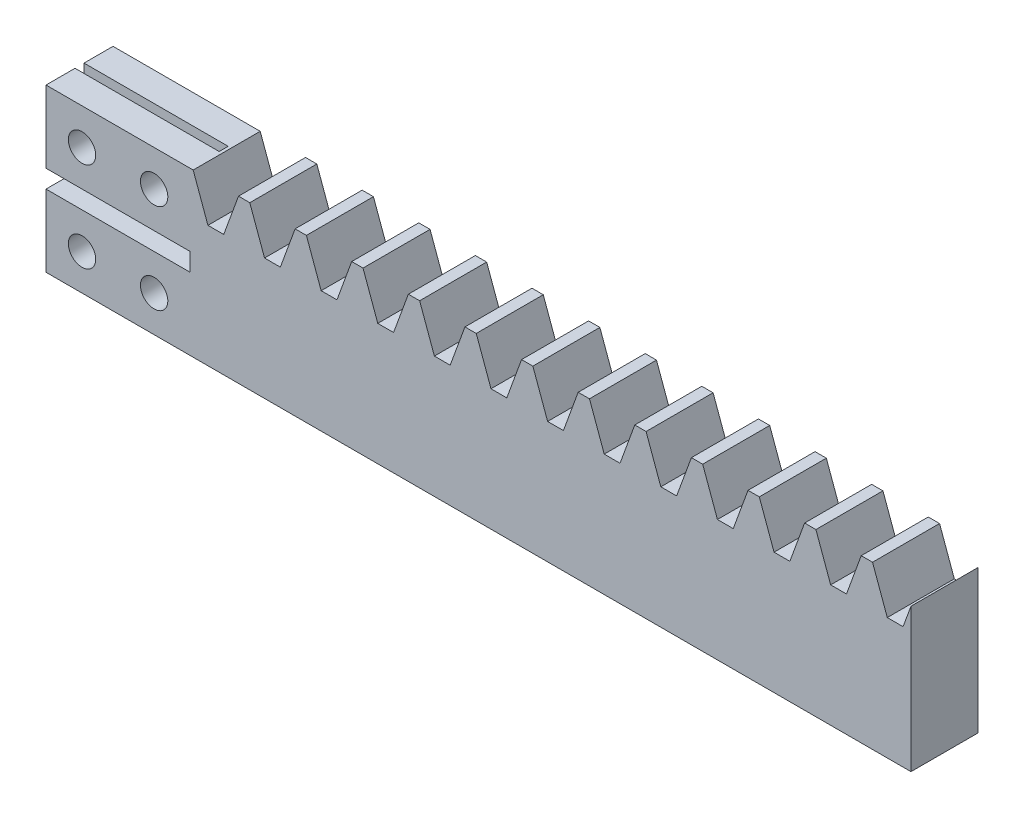
from build123d import *

# Parameters (mm, degrees)
BLANKSKE_W              = 152.4
BLANKSKE_H              = 28.575
BLANK_DEPTH             = 11.811
TOOTHCUTSIM_DEPTH       = 156.504952802
TEETHCUTS_COUNT         = 16
TEETHCUTS_PITCH         = 9.974556664
SKETCH2_W               = 23.941257987
SKETCH2_H               = 28.575
BOSS_EXTRUDE1_DEPTH     = 11.811
CUT_EXTRUDE1_DEPTH      = 156.504952802
CUT_EXTRUDE1_DEPTH_BACK = 156.504952802
CUT_EXTRUDE5_DEPTH      = 156.504952802
CUT_EXTRUDE5_DEPTH_BACK = 156.504952802
SKETCH5_R               = 2.413
CUT_EXTRUDE6_DEPTH      = 12.446


with BuildPart() as part:
    # BlankSke → Blank (new body)
    with BuildSketch(Plane.XY):
        with Locations((76.2, 14.2875)):
            Rectangle(BLANKSKE_W, BLANKSKE_H)
    extrude(amount=-BLANK_DEPTH)

    # TooCutSkeSim → ToothCutSim (cut, through all)
    with BuildSketch(Plane.XY):
        Polygon((1.392032299, 21.43125), (-1.392032299, 21.43125), (-4.001389504, 28.6004), (4.001389504, 28.6004), align=None)
    toothcutsim = extrude(amount=-TOOTHCUTSIM_DEPTH, mode=Mode.SUBTRACT)

    # TeethCuts: ToothCutSim ×16
    with Locations(*[(i * TEETHCUTS_PITCH, 0, 0) for i in range(1, TEETHCUTS_COUNT)]):
        add(toothcutsim, mode=Mode.SUBTRACT)

    # Sketch2 → Boss-Extrude1 (add)
    with BuildSketch(Plane.XY):
        with Locations((11.970628994, 14.2875)):
            Rectangle(SKETCH2_W, SKETCH2_H)
    extrude(amount=-BOSS_EXTRUDE1_DEPTH)

    # Sketch3 → Cut-Extrude1 (cut, two sides)
    with BuildSketch(Plane.XY) as cut_extrude1_sk:
        Polygon((-316.449184205, 12.7), (0, 12.7), (25.4, 12.7), (25.4, 15.875), (0, 15.875), (-316.449184205, 15.875), (-949.347552615, 15.875), (-949.347552615, 12.7), align=None)
    extrude(amount=CUT_EXTRUDE1_DEPTH, mode=Mode.SUBTRACT)
    extrude(cut_extrude1_sk.sketch, amount=-CUT_EXTRUDE1_DEPTH_BACK, mode=Mode.SUBTRACT)

    # Sketch4 → Cut-Extrude5 (cut, two sides)
    with BuildSketch(Plane(origin=(0, 28.575, 0), x_dir=(1, 0, 0), z_dir=(0, 1, 0))) as cut_extrude5_sk:
        Polygon((-315.09434574, 6.69925), (0, 6.69925), (25.4, 6.69925), (25.4, 5.11175), (0, 5.11175), (-315.09434574, 5.11175), (-945.283037219, 5.11175), (-945.283037219, 6.69925), align=None)
    extrude(amount=CUT_EXTRUDE5_DEPTH, mode=Mode.SUBTRACT)
    extrude(cut_extrude5_sk.sketch, amount=-CUT_EXTRUDE5_DEPTH_BACK, mode=Mode.SUBTRACT)

    # Sketch5 → Cut-Extrude6 (cut)
    with BuildSketch(Plane.XY):
        with Locations(Location((6.35, 22.225, 0), (0, 0, 180))):
            Circle(SKETCH5_R)
        with Locations(Location((19.05, 22.225, 0), (0, 0, 180))):
            Circle(SKETCH5_R)
        with Locations((19.05, 6.35)):
            Circle(SKETCH5_R)
        with Locations((6.35, 6.35)):
            Circle(SKETCH5_R)
    extrude(amount=-CUT_EXTRUDE6_DEPTH, mode=Mode.SUBTRACT)


solid = part.part
